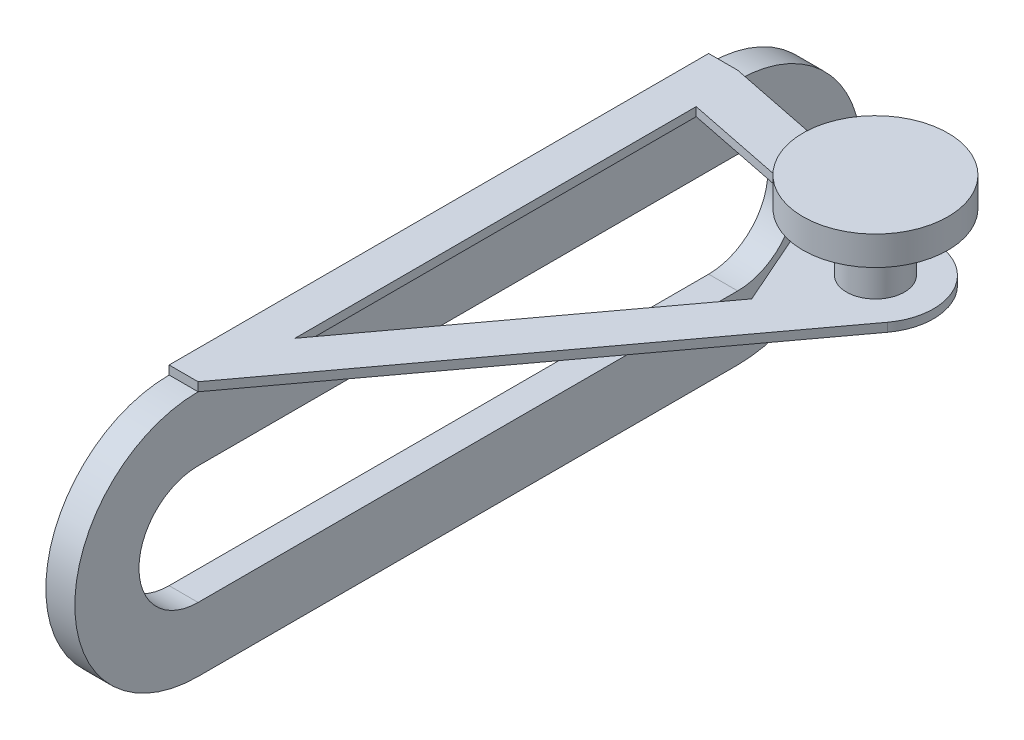
from build123d import *

# Parameters (mm, degrees)
BOSS_EXTRUDE1_DEPTH = 10
BOSS_EXTRUDE2_DEPTH = 3
SKETCH3_R           = 10
BOSS_EXTRUDE3_DEPTH = 20
CUT_EXTRUDE1_DEPTH  = 11
CUT_EXTRUDE2_DEPTH  = 89
SKETCH6_R           = 25
BOSS_EXTRUDE4_DEPTH = 10


with BuildPart() as part:
    # Sketch1 → Boss-Extrude1 (new body)
    with BuildSketch(Plane(origin=(0, 0, 0), x_dir=(0, -1, 0), z_dir=(-1, 0, 0))):
        with BuildLine():
            Line((-42.5, 186), (-42.5, 0))
            ThreePointArc((-42.5, 0), (0, -42.5), (42.5, 0))
            Line((42.5, 0), (42.5, 186))
            ThreePointArc((42.5, 186), (0, 228.5), (-42.5, 186))
        make_face()
    extrude(amount=-BOSS_EXTRUDE1_DEPTH)

    # Sketch2 → Boss-Extrude2 (add)
    with BuildSketch(Plane(origin=(0, 42.5, 0), x_dir=(-1, 0, 0), z_dir=(0, 1, 0))):
        with BuildLine():
            Line((-10, 0), (-98.944350751, 17.892804965))
            ThreePointArc((-98.944350751, 17.892804965), (-113.663663971, 30.311978912), (-111.07737178, 49.396138729))
            Line((-111.07737178, 49.396138729), (-10, 186))
            Line((-10, 186), (0, 186))
            Line((0, 186), (0, 0))
            Line((0, 0), (-10, 0))
        make_face()
    extrude(amount=BOSS_EXTRUDE2_DEPTH)

    # Sketch3 → Boss-Extrude3 (add)
    with BuildSketch(Plane(origin=(0, 45.5, 0), x_dir=(-1, 0, 0), z_dir=(0, 1, 0))):
        with Locations((-95, 37.5)):
            Circle(SKETCH3_R)
    extrude(amount=BOSS_EXTRUDE3_DEPTH)

    # Sketch4 → Cut-Extrude1 (cut, through all)
    with BuildSketch(Plane(origin=(10, 0, 0), x_dir=(0, 0, -1), z_dir=(1, 0, 0))):
        with BuildLine():
            Line((0, 20.390002673), (-186, 20.390002673))
            ThreePointArc((-186, 20.390002673), (-206.390002673, 0), (-186, -20.390002673))
            Line((-186, -20.390002673), (0, -20.390002673))
            ThreePointArc((0, -20.390002673), (20.390002673, 0), (0, 20.390002673))
        make_face()
    extrude(amount=-CUT_EXTRUDE1_DEPTH, mode=Mode.SUBTRACT)

    # Sketch5 → Cut-Extrude2 (cut, through all)
    with BuildSketch(Plane(origin=(0, 45.5, 0), x_dir=(-1, 0, 0), z_dir=(0, 1, 0))):
        Polygon((-64.102931729, 28.152292708), (-13.715935026, 18.016014269), (-13.715935026, 156.359237723), (-80.693023557, 65.841164794), align=None)
    extrude(amount=-CUT_EXTRUDE2_DEPTH, mode=Mode.SUBTRACT)

    # Sketch6 → Boss-Extrude4 (add)
    with BuildSketch(Plane(origin=(0, 65.5, 0), x_dir=(1, 0, 0), z_dir=(0, 1, 0))):
        with Locations((95, -37.5)):
            Circle(SKETCH6_R)
    extrude(amount=BOSS_EXTRUDE4_DEPTH)


solid = part.part
